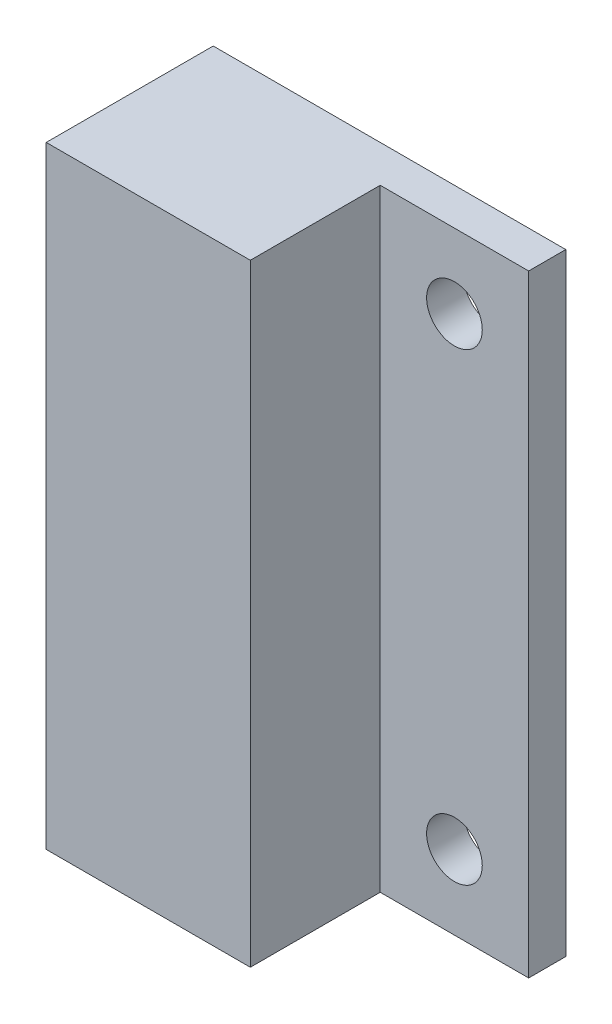
from build123d import *

# Parameters (mm, degrees)
SKETCH1_W                 = 19
SKETCH1_H                 = 33
BOSS_EXTRUDE1_DEPTH       = 9
SKETCH3_W                 = 8
SKETCH3_H                 = 33
CUT_EXTRUDE1_DEPTH        = 7
F_3_0MM_DOWEL_HOLE1_D     = 3
F_3_0MM_DOWEL_HOLE1_DEPTH = 2


with BuildPart() as part:
    # Sketch1 → Boss-Extrude1 (new body)
    with BuildSketch(Plane.XY):
        with Locations((9.5, 16.5)):
            Rectangle(SKETCH1_W, SKETCH1_H)
    extrude(amount=BOSS_EXTRUDE1_DEPTH)

    # Sketch3 → Cut-Extrude1 (cut)
    with BuildSketch(Plane.XY.offset(9)):
        with Locations((15, 16.5)):
            Rectangle(SKETCH3_W, SKETCH3_H)
    extrude(amount=-CUT_EXTRUDE1_DEPTH, mode=Mode.SUBTRACT)

    # Ø3.0mm Dowel Hole1
    with Locations(Plane.XY.offset(2)):
        with Locations((15, 4), (15, 29)):
            Hole(F_3_0MM_DOWEL_HOLE1_D / 2, depth=F_3_0MM_DOWEL_HOLE1_DEPTH)


solid = part.part
